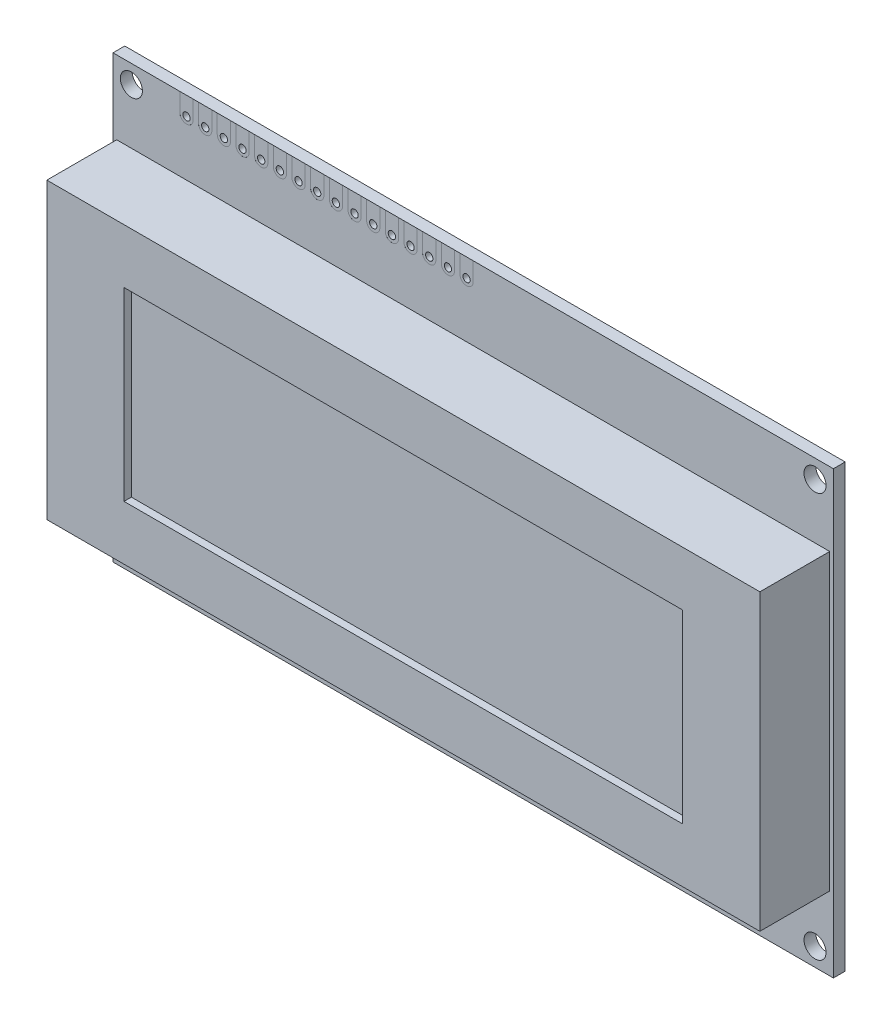
from build123d import *

# Parameters (mm, degrees)
CROQUIS1_W              = 98
CROQUIS1_H              = 60
SALIENTE_EXTRUIR1_DEPTH = 0.8
CROQUIS2_R              = 1.5
CORTAR_EXTRUIR1_DEPTH   = 2.6
CROQUIS3_W              = 97
CROQUIS3_H              = 40
SALIENTE_EXTRUIR2_DEPTH = 9.5
CROQUIS4_W              = 76
CROQUIS4_H              = 25.2
CORTAR_EXTRUIR2_DEPTH   = 1
CORTAR_EXTRUIR5_START   = -8.5
CROQUIS5_R              = 0.5
CORTAR_EXTRUIR5_DEPTH   = 0.001
CROQUIS5_2_R            = 0.5
CORTAR_EXTRUIR6_DEPTH   = 11.1
MATRIZL1_COUNT          = 16
MATRIZL1_PITCH          = 2.54


with BuildPart() as part:
    # Croquis1 → Saliente-Extruir1 (new body, symmetric)
    with BuildSketch(Plane.XY):
        Rectangle(CROQUIS1_W, CROQUIS1_H)
    extrude(amount=SALIENTE_EXTRUIR1_DEPTH, both=True)

    # Croquis2 → Cortar-Extruir1 (cut, through all)
    with BuildSketch(Plane.XY.offset(0.8)):
        with Locations((-46.5, 27.5)):
            Circle(CROQUIS2_R)
        with Locations((-46.5, -27.5)):
            Circle(CROQUIS2_R)
        with Locations((46.5, -27.5)):
            Circle(CROQUIS2_R)
        with Locations((46.5, 27.5)):
            Circle(CROQUIS2_R)
    extrude(amount=-CORTAR_EXTRUIR1_DEPTH, mode=Mode.SUBTRACT)

    # Croquis3 → Saliente-Extruir2 (add)
    with BuildSketch(Plane.XY.offset(0.8)):
        Rectangle(CROQUIS3_W, CROQUIS3_H)
    extrude(amount=SALIENTE_EXTRUIR2_DEPTH)

    # Croquis4 → Cortar-Extruir2 (cut)
    with BuildSketch(Plane.XY.offset(10.3)):
        Rectangle(CROQUIS4_W, CROQUIS4_H)
    extrude(amount=-CORTAR_EXTRUIR2_DEPTH, mode=Mode.SUBTRACT)

    # Croquis5 → Cortar-Extruir5 (cut)
    with BuildSketch(Plane.XY.offset(9.3).offset(CORTAR_EXTRUIR5_START)):
        with BuildLine():
            Line((-39.9, 30), (-38.1, 30))
            Line((-38.1, 30), (-38.1, 27.5))
            ThreePointArc((-38.1, 27.5), (-39, 26.6), (-39.9, 27.5))
            Line((-39.9, 27.5), (-39.9, 30))
        make_face()
        with Locations((-39, 27.5)):
            Circle(CROQUIS5_R, mode=Mode.SUBTRACT)
    cortar_extruir5 = extrude(amount=-CORTAR_EXTRUIR5_DEPTH, mode=Mode.SUBTRACT)

    # Croquis5_2 → Cortar-Extruir6 (cut, through all)
    with BuildSketch(Plane.XY.offset(9.3)):
        with Locations((-39, 27.5)):
            Circle(CROQUIS5_2_R)
    cortar_extruir6 = extrude(amount=-CORTAR_EXTRUIR6_DEPTH, mode=Mode.SUBTRACT)

    # MatrizL1: Cortar-Extruir5, Cortar-Extruir6 ×16
    with Locations(*[(i * MATRIZL1_PITCH, 0, 0) for i in range(1, MATRIZL1_COUNT)]):
        add(cortar_extruir5, mode=Mode.SUBTRACT)
        add(cortar_extruir6, mode=Mode.SUBTRACT)


solid = part.part
